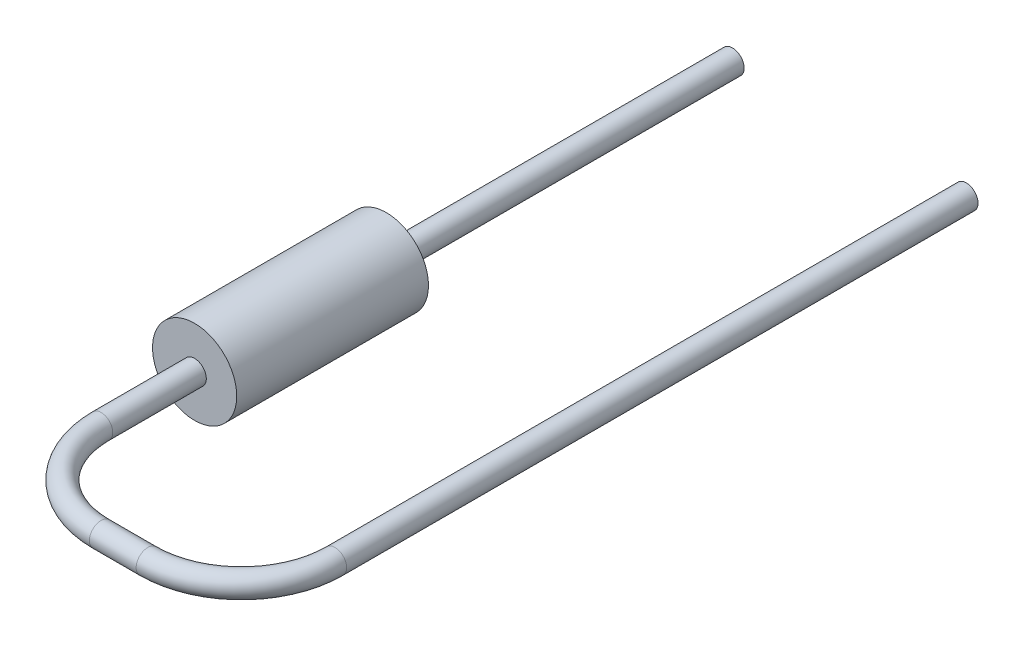
from build123d import *

# Parameters (mm, degrees)
SKETCH2_R           = 0.9
RESISTOR_BODY_DEPTH = 4.1
LEAD1_PROFILE_R     = 0.25
LEAD2_START         = -7.4
SKETCH6_R           = 0.25
LEAD2_DEPTH         = 7.4


with BuildPart() as part:
    # Sketch2 → Resistor Body (new body)
    with BuildSketch(Plane.XY):
        Circle(SKETCH2_R)
    extrude(amount=RESISTOR_BODY_DEPTH)

    # Lead1: sweep along a path in Lead1 Path
    with BuildLine(Plane(origin=(0, 0, 0), x_dir=(1, 0, 0), z_dir=(0, 1, 0))) as lead1_path:
        Line((5, 7.4), (5, -6.1))
        ThreePointArc((5, -6.1), (4.414213562, -7.514213562), (3, -8.1))
        Line((3, -8.1), (2, -8.1))
        ThreePointArc((2, -8.1), (0.585786438, -7.514213562), (0, -6.1))
        Line((0, -6.1), (0, -4.1))
    # Lead1 Profile → Lead1 (sweep)
    with BuildSketch(Plane(origin=(0, 0, 4.1), x_dir=(-1, 0, 0), z_dir=(0, 0, 1))):
        Circle(LEAD1_PROFILE_R)
    sweep(path=lead1_path.line)

    # Sketch6 → Lead2 (add)
    with BuildSketch(Plane.XY.offset(LEAD2_START)):
        Circle(SKETCH6_R)
    extrude(amount=LEAD2_DEPTH)


solid = part.part
